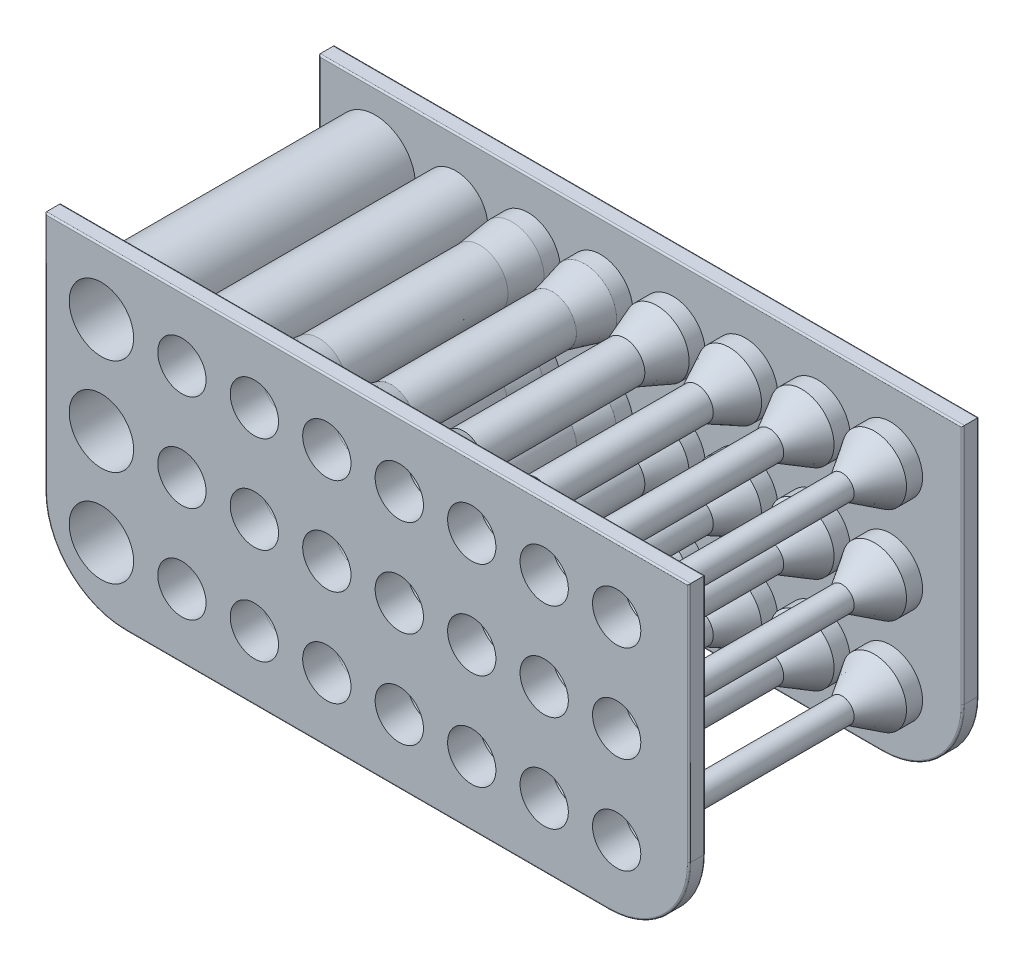
from build123d import *

# Parameters (mm, degrees)
SKIZZE1_R                          = 5
SKIZZE1_R_2                        = 4
EXTRUDE_THIN2_DEPTH                = 18
SKIZZE1_R_3                        = 3
EXTRUDE_THIN2_2_DEPTH              = 18
SKIZZE1_R_4                        = 3.5
SKIZZE1_R_5                        = 2.5
EXTRUDE_THIN2_3_DEPTH              = 18
SKIZZE1_R_6                        = 2
EXTRUDE_THIN2_4_DEPTH              = 18
SKIZZE1_R_7                        = 1.5
EXTRUDE_THIN2_5_DEPTH              = 18
SKIZZE1_R_8                        = 1
EXTRUDE_THIN2_6_DEPTH              = 18
SKIZZE1_R_9                        = 1.75
SKIZZE1_R_10                       = 0.75
EXTRUDE_THIN2_7_DEPTH              = 18
SKIZZE1_R_11                       = 0.5
EXTRUDE_THIN2_8_DEPTH              = 18
SKETCH1_W                          = 80
SKETCH1_H                          = 40
BOSS_EXTRUDE1_DEPTH                = 2
FILLET1_R                          = 10
LPATTERN2_COUNT                    = 2
LPATTERN2_PITCH                    = 34
FILLET1_OF_LPATTERN2_R             = 10
SKIZZE1_3_R                        = 4
SKIZZE1_3_R_2                      = 3
SKIZZE1_3_R_3                      = 2.5
SKIZZE1_3_R_4                      = 2
SKIZZE1_3_R_5                      = 1.5
SKIZZE1_3_R_6                      = 1
SKIZZE1_3_R_7                      = 0.75
SKIZZE1_3_R_8                      = 0.5
CUT_EXTRUDE1_DEPTH                 = 18
SKETCH7_R                          = 4
CUT_EXTRUDE2_DEPTH                 = 8
SKETCH7_3_R                        = 4
SKETCH7_3_R_2                      = 3
EXTRUDE_THIN3_DEPTH                = 4
FILLET3_R                          = 0.2
LINEARES_MUSTER1_COUNT             = 2
LINEARES_MUSTER1_PITCH             = 12
LINEARES_MUSTER1_COUNT_DIR2        = 2
LINEARES_MUSTER1_PITCH_DIR2        = 12
LINEARES_MUSTER1_COPY_1_SKETCH_R   = 4
LINEARES_MUSTER1_COPY_1_DEPTH      = 8
LINEARES_MUSTER1_COPY_2_SKETCH_R   = 4
LINEARES_MUSTER1_COPY_2_DEPTH      = 8
LINEARES_MUSTER1_COPY_3_SKETCH_R   = 4
LINEARES_MUSTER1_COPY_3_DEPTH      = 8
LINEARES_MUSTER1_COPY_4_SKETCH_R   = 4
LINEARES_MUSTER1_COPY_4_SKETCH_R_2 = 3
LINEARES_MUSTER1_COPY_4_DEPTH      = 4
LINEARES_MUSTER1_COPY_5_SKETCH_R   = 4
LINEARES_MUSTER1_COPY_5_SKETCH_R_2 = 3
LINEARES_MUSTER1_COPY_5_DEPTH      = 4
LINEARES_MUSTER1_COPY_6_SKETCH_R   = 4
LINEARES_MUSTER1_COPY_6_SKETCH_R_2 = 3
LINEARES_MUSTER1_COPY_6_DEPTH      = 4


with BuildPart() as part:
    # Skizze1 → Extrude-Thin2 (new, symmetric)
    with BuildSketch(Plane.XY):
        with Locations((-33, 0)):
            Circle(SKIZZE1_R)
        with Locations((-33, 0)):
            Circle(SKIZZE1_R_2, mode=Mode.SUBTRACT)
    extrude_thin2 = extrude(amount=EXTRUDE_THIN2_DEPTH, both=True)



with BuildPart() as body_2:
    # Skizze1 → Extrude-Thin2 2 (new, symmetric)
    with BuildSketch(Plane.XY):
        with Locations((-23, 0)):
            Circle(SKIZZE1_R_2)
        with Locations((-23, 0)):
            Circle(SKIZZE1_R_3, mode=Mode.SUBTRACT)
    extrude_thin2_2 = extrude(amount=EXTRUDE_THIN2_2_DEPTH, both=True)


with BuildPart() as body_3:
    # Skizze1 → Extrude-Thin2 3 (new, symmetric)
    with BuildSketch(Plane.XY):
        with Locations((-14, 0)):
            Circle(SKIZZE1_R_4)
        with Locations((-14, 0)):
            Circle(SKIZZE1_R_5, mode=Mode.SUBTRACT)
    extrude_thin2_3 = extrude(amount=EXTRUDE_THIN2_3_DEPTH, both=True)


with BuildPart() as body_4:
    # Skizze1 → Extrude-Thin2 4 (new, symmetric)
    with BuildSketch(Plane.XY):
        with Locations((-5, 0)):
            Circle(SKIZZE1_R_3)
        with Locations((-5, 0)):
            Circle(SKIZZE1_R_6, mode=Mode.SUBTRACT)
    extrude_thin2_4 = extrude(amount=EXTRUDE_THIN2_4_DEPTH, both=True)


with BuildPart() as body_5:
    # Skizze1 → Extrude-Thin2 5 (new, symmetric)
    with BuildSketch(Plane.XY):
        with Locations((4, 0)):
            Circle(SKIZZE1_R_5)
        with Locations((4, 0)):
            Circle(SKIZZE1_R_7, mode=Mode.SUBTRACT)
    extrude_thin2_5 = extrude(amount=EXTRUDE_THIN2_5_DEPTH, both=True)


with BuildPart() as body_6:
    # Skizze1 → Extrude-Thin2 6 (new, symmetric)
    with BuildSketch(Plane.XY):
        with Locations((13, 0)):
            Circle(SKIZZE1_R_6)
        with Locations((13, 0)):
            Circle(SKIZZE1_R_8, mode=Mode.SUBTRACT)
    extrude_thin2_6 = extrude(amount=EXTRUDE_THIN2_6_DEPTH, both=True)


with BuildPart() as body_7:
    # Skizze1 → Extrude-Thin2 7 (new, symmetric)
    with BuildSketch(Plane.XY):
        with Locations((22, 0)):
            Circle(SKIZZE1_R_9)
        with Locations((22, 0)):
            Circle(SKIZZE1_R_10, mode=Mode.SUBTRACT)
    extrude_thin2_7 = extrude(amount=EXTRUDE_THIN2_7_DEPTH, both=True)


with BuildPart() as body_8:
    # Skizze1 → Extrude-Thin2 8 (new, symmetric)
    with BuildSketch(Plane.XY):
        with Locations((31, 0)):
            Circle(SKIZZE1_R_7)
        with Locations((31, 0)):
            Circle(SKIZZE1_R_11, mode=Mode.SUBTRACT)
    extrude_thin2_8 = extrude(amount=EXTRUDE_THIN2_8_DEPTH, both=True)


with BuildPart() as part_1:
    add(part.part)

    add(body_2.part)  # Boss-Extrude1 merges body 2

    add(body_3.part)  # Boss-Extrude1 merges body 3

    add(body_4.part)  # Boss-Extrude1 merges body 4

    add(body_5.part)  # Boss-Extrude1 merges body 5

    add(body_6.part)  # Boss-Extrude1 merges body 6

    add(body_7.part)  # Boss-Extrude1 merges body 7

    add(body_8.part)  # Boss-Extrude1 merges body 8
    # Sketch1 → Boss-Extrude1 (add)
    with BuildSketch(Plane.XY.offset(18)):
        Rectangle(SKETCH1_W, SKETCH1_H)
    boss_extrude1 = extrude(amount=-BOSS_EXTRUDE1_DEPTH)

    # Fillet1
    fillet1_edges = [part_1.edges().sort_by_distance(p)[0] for p in [
        (40, -20, 17),
        (-40, -20, 17),
    ]]
    fillet(fillet1_edges, radius=FILLET1_R)

    # LPattern2: Boss-Extrude1 ×2
    with Locations(*[(0, 0, -i * LPATTERN2_PITCH) for i in range(1, LPATTERN2_COUNT)]):
        add(boss_extrude1)

    # Fillet1 of LPattern2
    fillet1_of_lpattern2_edges = [part_1.edges().sort_by_distance(p)[0] for p in [
        (40, -20, -17),
        (-40, -20, -17),
    ]]
    fillet(fillet1_of_lpattern2_edges, radius=FILLET1_OF_LPATTERN2_R)

    # Skizze1_3 → Cut-Extrude1 (cut, symmetric)
    with BuildSketch(Plane.XY):
        with Locations((-33, 0)):
            Circle(SKIZZE1_3_R)
        with Locations((-23, 0)):
            Circle(SKIZZE1_3_R_2)
        with Locations((-14, 0)):
            Circle(SKIZZE1_3_R_3)
        with Locations((-5, 0)):
            Circle(SKIZZE1_3_R_4)
        with Locations((4, 0)):
            Circle(SKIZZE1_3_R_5)
        with Locations((13, 0)):
            Circle(SKIZZE1_3_R_6)
        with Locations((22, 0)):
            Circle(SKIZZE1_3_R_7)
        with Locations((31, 0)):
            Circle(SKIZZE1_3_R_8)
    cut_extrude1 = extrude(amount=CUT_EXTRUDE1_DEPTH, both=True, mode=Mode.SUBTRACT)

    # Sketch7 → Cut-Extrude2 (cut)
    with BuildSketch(Plane.XY.offset(18)):
        with Locations((31, 0)):
            Circle(SKETCH7_R)
        with Locations((22, 0)):
            Circle(SKETCH7_R)
        with Locations((13, 0)):
            Circle(SKETCH7_R)
        with Locations((4, 0)):
            Circle(SKETCH7_R)
        with Locations((-5, 0)):
            Circle(SKETCH7_R)
        with Locations((-14, 0)):
            Circle(SKETCH7_R)
    cut_extrude2 = extrude(amount=-CUT_EXTRUDE2_DEPTH, mode=Mode.SUBTRACT)

    # Sketch7_3 → Extrude-Thin3 (add)
    with BuildSketch(Plane.XY.offset(18)):
        with Locations((31, 0)):
            Circle(SKETCH7_3_R)
        with Locations((31, 0)):
            Circle(SKETCH7_3_R_2, mode=Mode.SUBTRACT)
        with Locations((22, 0)):
            Circle(SKETCH7_3_R)
        with Locations((22, 0)):
            Circle(SKETCH7_3_R_2, mode=Mode.SUBTRACT)
        with Locations((13, 0)):
            Circle(SKETCH7_3_R)
        with Locations((13, 0)):
            Circle(SKETCH7_3_R_2, mode=Mode.SUBTRACT)
        with Locations((4, 0)):
            Circle(SKETCH7_3_R)
        with Locations((4, 0)):
            Circle(SKETCH7_3_R_2, mode=Mode.SUBTRACT)
        with Locations((-5, 0)):
            Circle(SKETCH7_3_R)
        with Locations((-5, 0)):
            Circle(SKETCH7_3_R_2, mode=Mode.SUBTRACT)
        with Locations((-14, 0)):
            Circle(SKETCH7_3_R)
        with Locations((-14, 0)):
            Circle(SKETCH7_3_R_2, mode=Mode.SUBTRACT)
    extrude_thin3 = extrude(amount=-EXTRUDE_THIN3_DEPTH)

    # Sketch8 → Revolve2 (revolve)
    with BuildSketch(Plane(origin=(0, 0, 0), x_dir=(1, 0, 0), z_dir=(0, 1, 0))):
        Polygon((7, -14), (8, -14), (6.5, -10), (5.5, -10), align=None)
    revolve2 = revolve(axis=Axis((4, 0, 14), (0, 0, 1)))

    # Sketch22 → Revolve3 (revolve)
    with BuildSketch(Plane(origin=(0, 0, 0), x_dir=(1, 0, 0), z_dir=(0, 1, 0))):
        Polygon((15, -10), (17, -14), (16, -14), (14, -10), align=None)
    revolve3 = revolve(axis=Axis((13, 0, 14), (0, 0, 1)))

    # Sketch23 → Revolve4 (revolve)
    with BuildSketch(Plane(origin=(0, 0, 0), x_dir=(1, 0, 0), z_dir=(0, 1, 0))):
        Polygon((23.75, -10), (26, -14), (25, -14), (22.75, -10), align=None)
    revolve4 = revolve(axis=Axis((22, 0, 14), (0, 0, 1)))

    # Sketch24 → Revolve5 (revolve)
    with BuildSketch(Plane(origin=(0, 0, 0), x_dir=(1, 0, 0), z_dir=(0, 1, 0))):
        Polygon((35, -14), (34, -14), (31.5, -10), (32.5, -10), align=None)
    revolve5 = revolve(axis=Axis((31, 0, 14), (0, 0, 1)))

    # Skizze2 → Rotation1 (revolve)
    with BuildSketch(Plane(origin=(0, 0, 0), x_dir=(1, 0, 0), z_dir=(0, 1, 0))):
        Polygon((-2, -10), (-1, -14), (-2, -14), (-3, -10), align=None)
    rotation1 = revolve(axis=Axis((-5, 0, 14), (0, 0, 1)))

    # Skizze3 → Rotation2 (revolve)
    with BuildSketch(Plane(origin=(0, 0, 0), x_dir=(1, 0, 0), z_dir=(0, 1, 0))):
        Polygon((-10.5, -10), (-10, -14), (-11, -14), (-11.5, -10), align=None)
    rotation2 = revolve(axis=Axis((-14, 0, 14), (0, 0, 1)))

    # Fillet3
    fillet3_edges = [part_1.edges().sort_by_distance(p)[0] for p in [
        (-38, 0, -16),
        (-27, 0, -16),
        (-17.5, 0, -16),
        (-8, 0, -16),
        (1.5, 0, -16),
        (11, 0, -16),
        (20.25, 0, -16),
        (29.5, 0, -16),
        (-40, 5, -18),
        (0, 20, -18),
        (0, 20, -16),
        (-40, 5, -16),
        (-40, 5, 16),
        (0, 20, 16),
        (0, 20, 18),
        (-40, 5, 18),
        (0, -20, -16),
        (0, -20, -18),
        (40, 5, -16),
        (-37.071067812, -17.071067812, -16),
        (37.071067812, -17.071067812, -16),
        (40, 5, -18),
        (-37.071067812, -17.071067812, -18),
        (37.071067812, -17.071067812, -18),
        (-37, 0, -18),
        (-37, 0, 18),
        (-26, 0, -18),
        (-26, 0, 18),
        (-16.5, 0, -18),
        (-7, 0, -18),
        (2.5, 0, -18),
        (12, 0, -18),
        (21.25, 0, -18),
        (30.5, 0, -18),
        (-27, 0, 16),
        (27, 0, 16),
        (28, 0, 18),
        (18, 0, 16),
        (19, 0, 18),
        (9, 0, 16),
        (10, 0, 18),
        (0, 0, 16),
        (1, 0, 18),
        (-9, 0, 16),
        (-8, 0, 18),
        (-18, 0, 16),
        (-17, 0, 18),
        (0, -20, 18),
        (0, -20, 16),
        (40, 5, 18),
        (-37.071067812, -17.071067812, 18),
        (37.071067812, -17.071067812, 18),
        (40, 5, 16),
        (-37.071067812, -17.071067812, 16),
        (37.071067812, -17.071067812, 16),
        (-38, 0, 16),
    ]]
    fillet(fillet3_edges, radius=FILLET3_R)

    # Spiegeln1: Cut-Extrude2, Extrude-Thin3, Revolve2, Revolve3, Revolve4, Revolve5, Rotation1, Rotation2 across plane
    add(cut_extrude2.mirror(Plane.XY), mode=Mode.SUBTRACT)
    add(extrude_thin3.mirror(Plane.XY))
    add(revolve2.mirror(Plane.XY))
    add(revolve3.mirror(Plane.XY))
    add(revolve4.mirror(Plane.XY))
    add(revolve5.mirror(Plane.XY))
    add(rotation1.mirror(Plane.XY))
    add(rotation2.mirror(Plane.XY))

    # Lineares Muster1: Extrude-Thin2, Extrude-Thin2 2, Extrude-Thin2 3, Extrude-Thin2 4, Extrude-Thin2 5, Extrude-Thin2 6, Extrude-Thin2 7, Extrude-Thin2 8, Cut-Extrude1, Cut-Extrude2, Extrude-Thin3, Revolve2, Revolve3, Revolve4, Revolve5, Rotation1, Rotation2 2 × 2
    with Locations(*[Vector(0, -1, 0) * (i * LINEARES_MUSTER1_PITCH) + Vector(0, 1, 0) * (j * LINEARES_MUSTER1_PITCH_DIR2) for i in range(LINEARES_MUSTER1_COUNT) for j in range(LINEARES_MUSTER1_COUNT_DIR2) if (i, j) != (0, 0)]):
        add(extrude_thin2)
        add(extrude_thin2_2)
        add(extrude_thin2_3)
        add(extrude_thin2_4)
        add(extrude_thin2_5)
        add(extrude_thin2_6)
        add(extrude_thin2_7)
        add(extrude_thin2_8)
        add(cut_extrude1, mode=Mode.SUBTRACT)
        add(cut_extrude2, mode=Mode.SUBTRACT)
        add(extrude_thin3)
        add(revolve2)
        add(revolve3)
        add(revolve4)
        add(revolve5)
        add(rotation1)
        add(rotation2)

    # Lineares Muster1 copy 1 sketch → Lineares Muster1 copy 1 (cut)
    with BuildSketch(Plane(origin=(0, 12, -18), x_dir=(1, 0, 0), z_dir=(0, 0, -1))):
        with Locations((31, 0)):
            Circle(LINEARES_MUSTER1_COPY_1_SKETCH_R)
        with Locations((22, 0)):
            Circle(LINEARES_MUSTER1_COPY_1_SKETCH_R)
        with Locations((13, 0)):
            Circle(LINEARES_MUSTER1_COPY_1_SKETCH_R)
        with Locations((4, 0)):
            Circle(LINEARES_MUSTER1_COPY_1_SKETCH_R)
        with Locations((-5, 0)):
            Circle(LINEARES_MUSTER1_COPY_1_SKETCH_R)
        with Locations((-14, 0)):
            Circle(LINEARES_MUSTER1_COPY_1_SKETCH_R)
    extrude(amount=-LINEARES_MUSTER1_COPY_1_DEPTH, mode=Mode.SUBTRACT)

    # Lineares Muster1 copy 2 sketch → Lineares Muster1 copy 2 (cut)
    with BuildSketch(Plane(origin=(0, -12, -18), x_dir=(1, 0, 0), z_dir=(0, 0, -1))):
        with Locations((31, 0)):
            Circle(LINEARES_MUSTER1_COPY_2_SKETCH_R)
        with Locations((22, 0)):
            Circle(LINEARES_MUSTER1_COPY_2_SKETCH_R)
        with Locations((13, 0)):
            Circle(LINEARES_MUSTER1_COPY_2_SKETCH_R)
        with Locations((4, 0)):
            Circle(LINEARES_MUSTER1_COPY_2_SKETCH_R)
        with Locations((-5, 0)):
            Circle(LINEARES_MUSTER1_COPY_2_SKETCH_R)
        with Locations((-14, 0)):
            Circle(LINEARES_MUSTER1_COPY_2_SKETCH_R)
    extrude(amount=-LINEARES_MUSTER1_COPY_2_DEPTH, mode=Mode.SUBTRACT)

    # Lineares Muster1 copy 3 sketch → Lineares Muster1 copy 3 (cut)
    with BuildSketch(Plane(origin=(0, 0, -18), x_dir=(1, 0, 0), z_dir=(0, 0, -1))):
        with Locations((31, 0)):
            Circle(LINEARES_MUSTER1_COPY_3_SKETCH_R)
        with Locations((22, 0)):
            Circle(LINEARES_MUSTER1_COPY_3_SKETCH_R)
        with Locations((13, 0)):
            Circle(LINEARES_MUSTER1_COPY_3_SKETCH_R)
        with Locations((4, 0)):
            Circle(LINEARES_MUSTER1_COPY_3_SKETCH_R)
        with Locations((-5, 0)):
            Circle(LINEARES_MUSTER1_COPY_3_SKETCH_R)
        with Locations((-14, 0)):
            Circle(LINEARES_MUSTER1_COPY_3_SKETCH_R)
    extrude(amount=-LINEARES_MUSTER1_COPY_3_DEPTH, mode=Mode.SUBTRACT)

    # Lineares Muster1 copy 4 sketch → Lineares Muster1 copy 4 (add)
    with BuildSketch(Plane(origin=(0, 12, -18), x_dir=(1, 0, 0), z_dir=(0, 0, -1))):
        with Locations((31, 0)):
            Circle(LINEARES_MUSTER1_COPY_4_SKETCH_R)
        with Locations((31, 0)):
            Circle(LINEARES_MUSTER1_COPY_4_SKETCH_R_2, mode=Mode.SUBTRACT)
        with Locations((22, 0)):
            Circle(LINEARES_MUSTER1_COPY_4_SKETCH_R)
        with Locations((22, 0)):
            Circle(LINEARES_MUSTER1_COPY_4_SKETCH_R_2, mode=Mode.SUBTRACT)
        with Locations((13, 0)):
            Circle(LINEARES_MUSTER1_COPY_4_SKETCH_R)
        with Locations((13, 0)):
            Circle(LINEARES_MUSTER1_COPY_4_SKETCH_R_2, mode=Mode.SUBTRACT)
        with Locations((4, 0)):
            Circle(LINEARES_MUSTER1_COPY_4_SKETCH_R)
        with Locations((4, 0)):
            Circle(LINEARES_MUSTER1_COPY_4_SKETCH_R_2, mode=Mode.SUBTRACT)
        with Locations((-5, 0)):
            Circle(LINEARES_MUSTER1_COPY_4_SKETCH_R)
        with Locations((-5, 0)):
            Circle(LINEARES_MUSTER1_COPY_4_SKETCH_R_2, mode=Mode.SUBTRACT)
        with Locations((-14, 0)):
            Circle(LINEARES_MUSTER1_COPY_4_SKETCH_R)
        with Locations((-14, 0)):
            Circle(LINEARES_MUSTER1_COPY_4_SKETCH_R_2, mode=Mode.SUBTRACT)
    extrude(amount=-LINEARES_MUSTER1_COPY_4_DEPTH)

    # Lineares Muster1 copy 5 sketch → Lineares Muster1 copy 5 (add)
    with BuildSketch(Plane(origin=(0, -12, -18), x_dir=(1, 0, 0), z_dir=(0, 0, -1))):
        with Locations((31, 0)):
            Circle(LINEARES_MUSTER1_COPY_5_SKETCH_R)
        with Locations((31, 0)):
            Circle(LINEARES_MUSTER1_COPY_5_SKETCH_R_2, mode=Mode.SUBTRACT)
        with Locations((22, 0)):
            Circle(LINEARES_MUSTER1_COPY_5_SKETCH_R)
        with Locations((22, 0)):
            Circle(LINEARES_MUSTER1_COPY_5_SKETCH_R_2, mode=Mode.SUBTRACT)
        with Locations((13, 0)):
            Circle(LINEARES_MUSTER1_COPY_5_SKETCH_R)
        with Locations((13, 0)):
            Circle(LINEARES_MUSTER1_COPY_5_SKETCH_R_2, mode=Mode.SUBTRACT)
        with Locations((4, 0)):
            Circle(LINEARES_MUSTER1_COPY_5_SKETCH_R)
        with Locations((4, 0)):
            Circle(LINEARES_MUSTER1_COPY_5_SKETCH_R_2, mode=Mode.SUBTRACT)
        with Locations((-5, 0)):
            Circle(LINEARES_MUSTER1_COPY_5_SKETCH_R)
        with Locations((-5, 0)):
            Circle(LINEARES_MUSTER1_COPY_5_SKETCH_R_2, mode=Mode.SUBTRACT)
        with Locations((-14, 0)):
            Circle(LINEARES_MUSTER1_COPY_5_SKETCH_R)
        with Locations((-14, 0)):
            Circle(LINEARES_MUSTER1_COPY_5_SKETCH_R_2, mode=Mode.SUBTRACT)
    extrude(amount=-LINEARES_MUSTER1_COPY_5_DEPTH)

    # Lineares Muster1 copy 6 sketch → Lineares Muster1 copy 6 (add)
    with BuildSketch(Plane(origin=(0, 0, -18), x_dir=(1, 0, 0), z_dir=(0, 0, -1))):
        with Locations((31, 0)):
            Circle(LINEARES_MUSTER1_COPY_6_SKETCH_R)
        with Locations((31, 0)):
            Circle(LINEARES_MUSTER1_COPY_6_SKETCH_R_2, mode=Mode.SUBTRACT)
        with Locations((22, 0)):
            Circle(LINEARES_MUSTER1_COPY_6_SKETCH_R)
        with Locations((22, 0)):
            Circle(LINEARES_MUSTER1_COPY_6_SKETCH_R_2, mode=Mode.SUBTRACT)
        with Locations((13, 0)):
            Circle(LINEARES_MUSTER1_COPY_6_SKETCH_R)
        with Locations((13, 0)):
            Circle(LINEARES_MUSTER1_COPY_6_SKETCH_R_2, mode=Mode.SUBTRACT)
        with Locations((4, 0)):
            Circle(LINEARES_MUSTER1_COPY_6_SKETCH_R)
        with Locations((4, 0)):
            Circle(LINEARES_MUSTER1_COPY_6_SKETCH_R_2, mode=Mode.SUBTRACT)
        with Locations((-5, 0)):
            Circle(LINEARES_MUSTER1_COPY_6_SKETCH_R)
        with Locations((-5, 0)):
            Circle(LINEARES_MUSTER1_COPY_6_SKETCH_R_2, mode=Mode.SUBTRACT)
        with Locations((-14, 0)):
            Circle(LINEARES_MUSTER1_COPY_6_SKETCH_R)
        with Locations((-14, 0)):
            Circle(LINEARES_MUSTER1_COPY_6_SKETCH_R_2, mode=Mode.SUBTRACT)
    extrude(amount=-LINEARES_MUSTER1_COPY_6_DEPTH)

    # Lineares Muster1 copy 7 sketch → Lineares Muster1 copy 7 (revolve)
    with BuildSketch(Plane(origin=(0, 12, 0), x_dir=(1, 0, 0), z_dir=(0, 1, 0))):
        Polygon((7, 14), (8, 14), (6.5, 10), (5.5, 10), align=None)
    revolve(axis=Axis((4, 12, -14), (0, 0, 1)))

    # Lineares Muster1 copy 8 sketch → Lineares Muster1 copy 8 (revolve)
    with BuildSketch(Plane(origin=(0, -12, 0), x_dir=(1, 0, 0), z_dir=(0, 1, 0))):
        Polygon((7, 14), (8, 14), (6.5, 10), (5.5, 10), align=None)
    revolve(axis=Axis((4, -12, -14), (0, 0, 1)))

    # Lineares Muster1 copy 9 sketch → Lineares Muster1 copy 9 (revolve)
    with BuildSketch(Plane(origin=(0, 0, 0), x_dir=(1, 0, 0), z_dir=(0, 1, 0))):
        Polygon((7, 14), (8, 14), (6.5, 10), (5.5, 10), align=None)
    revolve(axis=Axis((4, 0, -14), (0, 0, 1)))

    # Lineares Muster1 copy 10 sketch → Lineares Muster1 copy 10 (revolve)
    with BuildSketch(Plane(origin=(0, 12, 0), x_dir=(1, 0, 0), z_dir=(0, 1, 0))):
        Polygon((15, 10), (17, 14), (16, 14), (14, 10), align=None)
    revolve(axis=Axis((13, 12, -14), (0, 0, 1)))

    # Lineares Muster1 copy 11 sketch → Lineares Muster1 copy 11 (revolve)
    with BuildSketch(Plane(origin=(0, -12, 0), x_dir=(1, 0, 0), z_dir=(0, 1, 0))):
        Polygon((15, 10), (17, 14), (16, 14), (14, 10), align=None)
    revolve(axis=Axis((13, -12, -14), (0, 0, 1)))

    # Lineares Muster1 copy 12 sketch → Lineares Muster1 copy 12 (revolve)
    with BuildSketch(Plane(origin=(0, 0, 0), x_dir=(1, 0, 0), z_dir=(0, 1, 0))):
        Polygon((15, 10), (17, 14), (16, 14), (14, 10), align=None)
    revolve(axis=Axis((13, 0, -14), (0, 0, 1)))

    # Lineares Muster1 copy 13 sketch → Lineares Muster1 copy 13 (revolve)
    with BuildSketch(Plane(origin=(0, 12, 0), x_dir=(1, 0, 0), z_dir=(0, 1, 0))):
        Polygon((23.75, 10), (26, 14), (25, 14), (22.75, 10), align=None)
    revolve(axis=Axis((22, 12, -14), (0, 0, 1)))

    # Lineares Muster1 copy 14 sketch → Lineares Muster1 copy 14 (revolve)
    with BuildSketch(Plane(origin=(0, -12, 0), x_dir=(1, 0, 0), z_dir=(0, 1, 0))):
        Polygon((23.75, 10), (26, 14), (25, 14), (22.75, 10), align=None)
    revolve(axis=Axis((22, -12, -14), (0, 0, 1)))

    # Lineares Muster1 copy 15 sketch → Lineares Muster1 copy 15 (revolve)
    with BuildSketch(Plane(origin=(0, 0, 0), x_dir=(1, 0, 0), z_dir=(0, 1, 0))):
        Polygon((23.75, 10), (26, 14), (25, 14), (22.75, 10), align=None)
    revolve(axis=Axis((22, 0, -14), (0, 0, 1)))

    # Lineares Muster1 copy 16 sketch → Lineares Muster1 copy 16 (revolve)
    with BuildSketch(Plane(origin=(0, 12, 0), x_dir=(1, 0, 0), z_dir=(0, 1, 0))):
        Polygon((35, 14), (34, 14), (31.5, 10), (32.5, 10), align=None)
    revolve(axis=Axis((31, 12, -14), (0, 0, 1)))

    # Lineares Muster1 copy 17 sketch → Lineares Muster1 copy 17 (revolve)
    with BuildSketch(Plane(origin=(0, -12, 0), x_dir=(1, 0, 0), z_dir=(0, 1, 0))):
        Polygon((35, 14), (34, 14), (31.5, 10), (32.5, 10), align=None)
    revolve(axis=Axis((31, -12, -14), (0, 0, 1)))

    # Lineares Muster1 copy 18 sketch → Lineares Muster1 copy 18 (revolve)
    with BuildSketch(Plane(origin=(0, 0, 0), x_dir=(1, 0, 0), z_dir=(0, 1, 0))):
        Polygon((35, 14), (34, 14), (31.5, 10), (32.5, 10), align=None)
    revolve(axis=Axis((31, 0, -14), (0, 0, 1)))

    # Lineares Muster1 copy 19 sketch → Lineares Muster1 copy 19 (revolve)
    with BuildSketch(Plane(origin=(0, 12, 0), x_dir=(1, 0, 0), z_dir=(0, 1, 0))):
        Polygon((-2, 10), (-1, 14), (-2, 14), (-3, 10), align=None)
    revolve(axis=Axis((-5, 12, -14), (0, 0, 1)))

    # Lineares Muster1 copy 20 sketch → Lineares Muster1 copy 20 (revolve)
    with BuildSketch(Plane(origin=(0, -12, 0), x_dir=(1, 0, 0), z_dir=(0, 1, 0))):
        Polygon((-2, 10), (-1, 14), (-2, 14), (-3, 10), align=None)
    revolve(axis=Axis((-5, -12, -14), (0, 0, 1)))

    # Lineares Muster1 copy 21 sketch → Lineares Muster1 copy 21 (revolve)
    with BuildSketch(Plane(origin=(0, 0, 0), x_dir=(1, 0, 0), z_dir=(0, 1, 0))):
        Polygon((-2, 10), (-1, 14), (-2, 14), (-3, 10), align=None)
    revolve(axis=Axis((-5, 0, -14), (0, 0, 1)))

    # Lineares Muster1 copy 22 sketch → Lineares Muster1 copy 22 (revolve)
    with BuildSketch(Plane(origin=(0, 12, 0), x_dir=(1, 0, 0), z_dir=(0, 1, 0))):
        Polygon((-10.5, 10), (-10, 14), (-11, 14), (-11.5, 10), align=None)
    revolve(axis=Axis((-14, 12, -14), (0, 0, 1)))

    # Lineares Muster1 copy 23 sketch → Lineares Muster1 copy 23 (revolve)
    with BuildSketch(Plane(origin=(0, -12, 0), x_dir=(1, 0, 0), z_dir=(0, 1, 0))):
        Polygon((-10.5, 10), (-10, 14), (-11, 14), (-11.5, 10), align=None)
    revolve(axis=Axis((-14, -12, -14), (0, 0, 1)))

    # Lineares Muster1 copy 24 sketch → Lineares Muster1 copy 24 (revolve)
    with BuildSketch(Plane(origin=(0, 0, 0), x_dir=(1, 0, 0), z_dir=(0, 1, 0))):
        Polygon((-10.5, 10), (-10, 14), (-11, 14), (-11.5, 10), align=None)
    revolve(axis=Axis((-14, 0, -14), (0, 0, 1)))


solid = part_1.part
